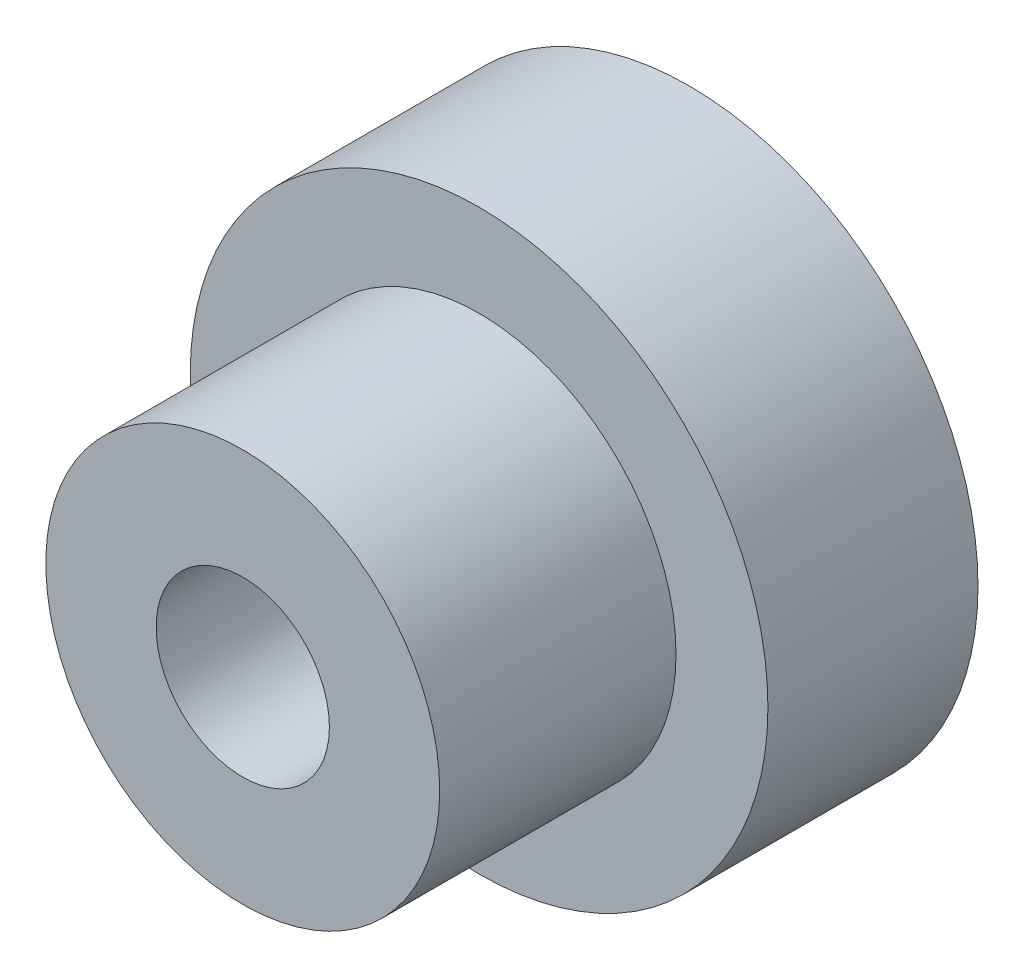
from build123d import *

# Parameters (mm, degrees)
SKETCH1_R           = 11
BOSS_EXTRUDE1_DEPTH = 8
SKETCH2_R           = 7.5
BOSS_EXTRUDE2_DEPTH = 9
SKETCH3_R           = 3.3
CUT_EXTRUDE1_DEPTH  = 18


with BuildPart() as part:
    # Sketch1 → Boss-Extrude1 (new body)
    with BuildSketch(Plane.XY):
        Circle(SKETCH1_R)
    extrude(amount=BOSS_EXTRUDE1_DEPTH)

    # Sketch2 → Boss-Extrude2 (add)
    with BuildSketch(Plane.XY.offset(8)):
        Circle(SKETCH2_R)
    extrude(amount=BOSS_EXTRUDE2_DEPTH)

    # Sketch3 → Cut-Extrude1 (cut, through all)
    with BuildSketch(Plane.XY.offset(17)):
        Circle(SKETCH3_R)
    extrude(amount=-CUT_EXTRUDE1_DEPTH, mode=Mode.SUBTRACT)


solid = part.part
